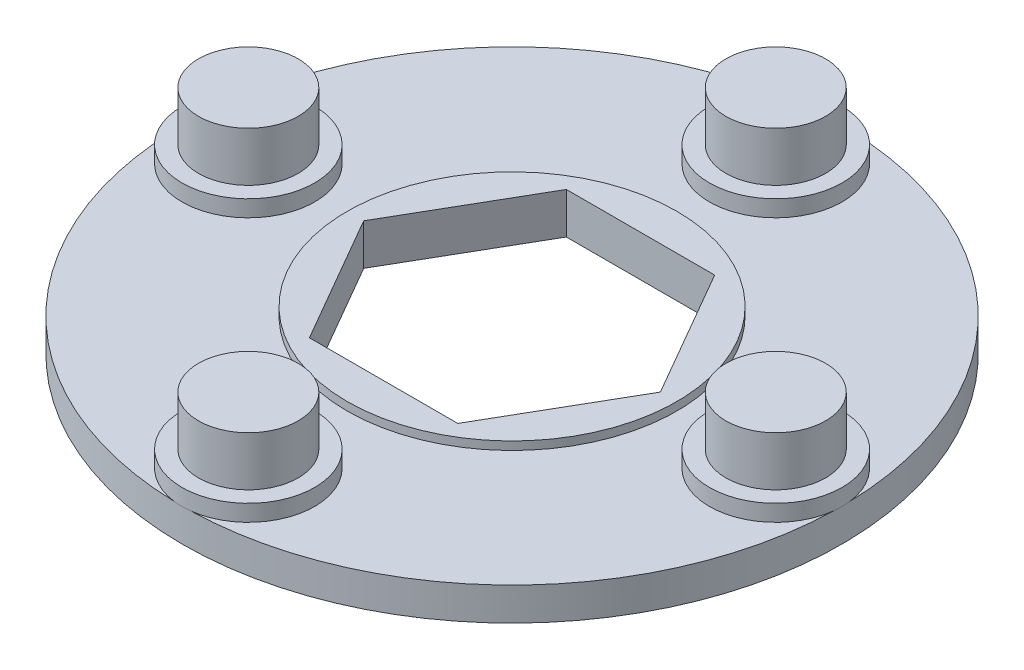
from build123d import *

# Parameters (mm, degrees)
ESQUISSE1_R             = 20
BOSS_EXTRU_1_DEPTH      = 2
ESQUISSE2_R             = 3.025
BOSS_EXTRU_2_DEPTH      = 4
ESQUISSE4_R             = 10
BOSS_EXTRU_3_DEPTH      = 0.5
ENL_V_MAT_EXTRU_1_DEPTH = 6
ESQUISSE5_R             = 4.025
BOSS_EXTRU_4_DEPTH      = 1


with BuildPart() as part:
    # Esquisse1 → Boss.-Extru.1 (new body)
    with BuildSketch(Plane(origin=(0, 0, 0), x_dir=(1, 0, 0), z_dir=(0, 1, 0))):
        Circle(ESQUISSE1_R)
    extrude(amount=BOSS_EXTRU_1_DEPTH)

    # Esquisse2 → Boss.-Extru.2 (add)
    with BuildSketch(Plane(origin=(0, 2, 0), x_dir=(1, 0, 0), z_dir=(0, 1, 0))):
        with Locations((0, 16)):
            Circle(ESQUISSE2_R)
        with Locations((16, 0)):
            Circle(ESQUISSE2_R)
        with Locations((0, -16)):
            Circle(ESQUISSE2_R)
        with Locations((-16, 0)):
            Circle(ESQUISSE2_R)
    extrude(amount=BOSS_EXTRU_2_DEPTH)

    # Esquisse4 → Boss.-Extru.3 (add)
    with BuildSketch(Plane(origin=(0, 2, 0), x_dir=(1, 0, 0), z_dir=(0, 1, 0))):
        Circle(ESQUISSE4_R)
    extrude(amount=BOSS_EXTRU_3_DEPTH)

    # Esquisse3 → Enlèv. mat.-Extru.1 (cut)
    with BuildSketch(Plane(origin=(0, 2.5, 0), x_dir=(1, 0, 0), z_dir=(0, 1, 0))):
        Polygon((4.5, -7.794228634), (9, 0), (4.5, 7.794228634), (-4.5, 7.794228634), (-9, 0), (-4.5, -7.794228634), align=None)
    extrude(amount=-ENL_V_MAT_EXTRU_1_DEPTH, mode=Mode.SUBTRACT)

    # Esquisse5 → Boss.-Extru.4 (add)
    with BuildSketch(Plane(origin=(0, 2, 0), x_dir=(1, 0, 0), z_dir=(0, 1, 0))):
        with Locations((16, 0)):
            Circle(ESQUISSE5_R)
        with Locations((0, 16)):
            Circle(ESQUISSE5_R)
        with Locations((0, -16)):
            Circle(ESQUISSE5_R)
        with Locations((-16, 0)):
            Circle(ESQUISSE5_R)
    extrude(amount=BOSS_EXTRU_4_DEPTH)


solid = part.part
